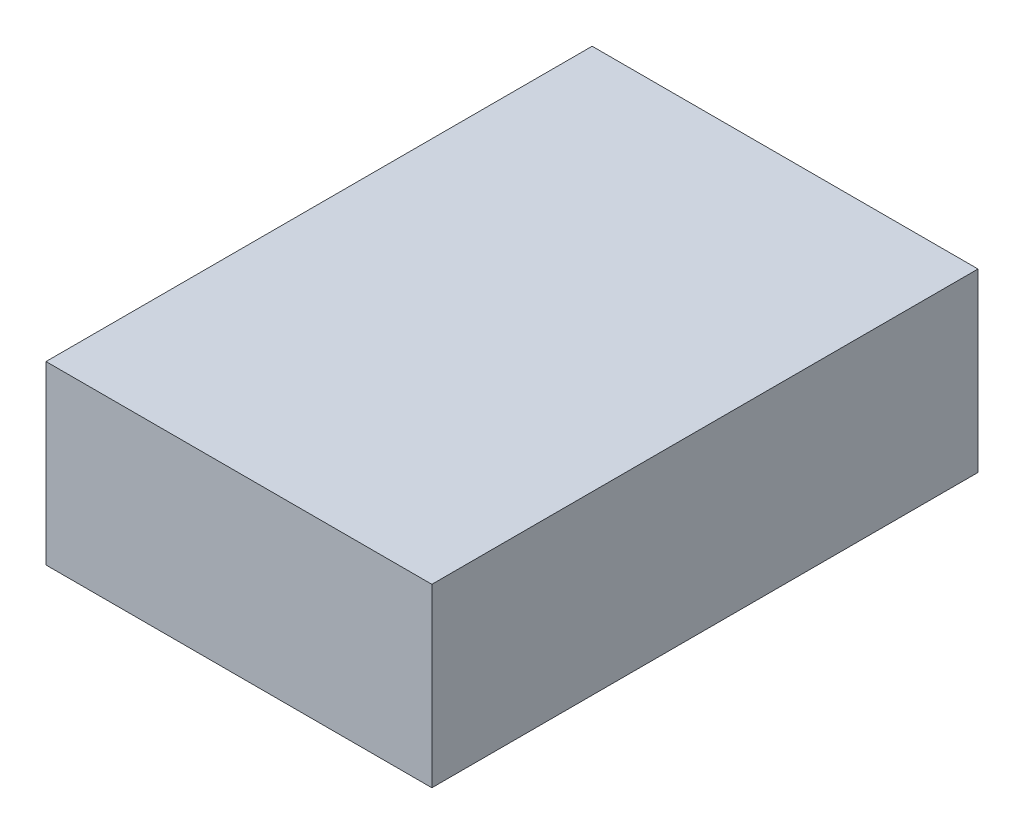
from build123d import *

# Parameters (mm, degrees)
SKETCH1_W           = 50.8
SKETCH1_H           = 71.9
BOSS_EXTRUDE1_DEPTH = 23.2


with BuildPart() as part:
    # Sketch1 → Boss-Extrude1 (new body)
    with BuildSketch(Plane(origin=(0, 0, 0), x_dir=(1, 0, 0), z_dir=(0, 1, 0))):
        Rectangle(SKETCH1_W, SKETCH1_H)
    extrude(amount=BOSS_EXTRUDE1_DEPTH)


solid = part.part
